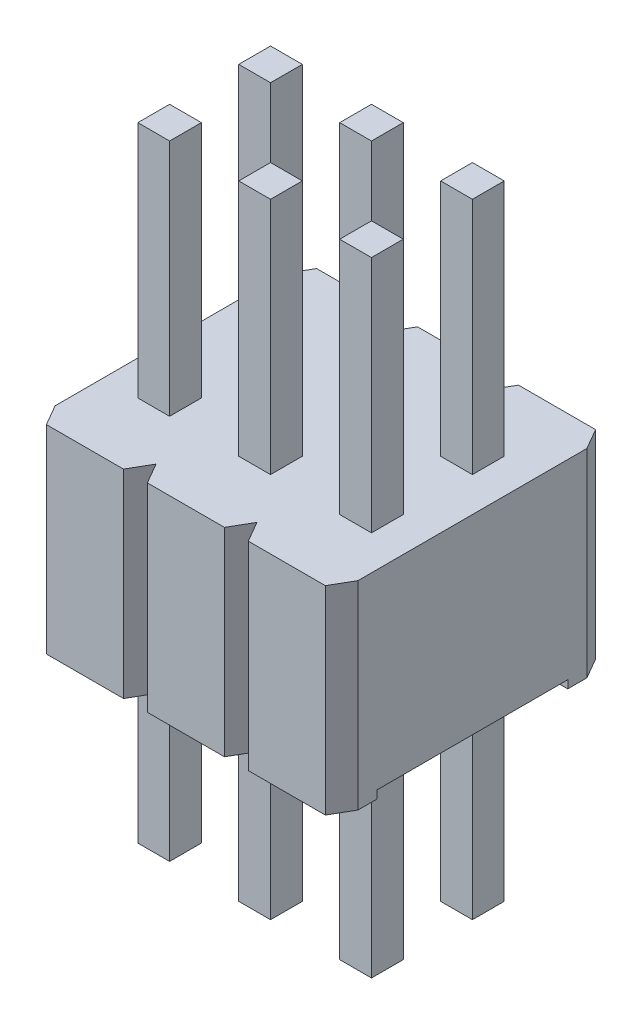
from build123d import *

# Parameters (mm, degrees)
SKETCH1_W             = 3.81
SKETCH1_H             = 3.4
BOSS_EXTRUDE1_DEPTH   = 2.5
CUT_EXTRUDE1_DEPTH    = 2.5
CUT_EXTRUDE2_DEPTH    = 2.5
CUT_EXTRUDE3_DEPTH    = 2.5
SKETCH5_W             = 2.4
SKETCH5_H             = 0.1
CUT_EXTRUDE4_DEPTH    = 4.81
CUT_EXTRUDE5_DEPTH    = 2.5
SKETCH7_W             = 0.4
SKETCH7_H             = 0.4
BOSS_EXTRUDE2_DEPTH   = 2.45
SKETCH8_W             = 0.4
SKETCH8_H             = 0.4
BOSS_EXTRUDE3_DEPTH   = 2.45
SKETCH9_W             = 0.4
SKETCH9_H             = 0.4
BOSS_EXTRUDE4_DEPTH   = 2.45
SKETCH10_W            = 0.4
SKETCH10_H            = 0.4
BOSS_EXTRUDE5_DEPTH   = 2.45
SKETCH11_W            = 0.4
SKETCH11_H            = 0.4
BOSS_EXTRUDE6_DEPTH   = 2.45
SKETCH12_W            = 0.4
SKETCH12_H            = 0.4
BOSS_EXTRUDE7_DEPTH   = 2.45
SKETCH13_W            = 0.4
SKETCH13_H            = 0.4
BOSS_EXTRUDE8_DEPTH   = 3
SKETCH14_W            = 0.4
SKETCH14_H            = 0.4
BOSS_EXTRUDE9_DEPTH   = 3
SKETCH15_W            = 0.4
SKETCH15_H            = 0.4
BOSS_EXTRUDE10_DEPTH  = 3
SKETCH16_W            = 0.4
SKETCH16_H            = 0.4
BOSS_EXTRUDE11_DEPTH  = 3
SKETCH17_W            = 0.4
SKETCH17_H            = 0.4
BOSS_EXTRUDE12_DEPTH  = 3
SKETCH18_W            = 0.4
SKETCH18_H            = 0.4
BOSS_EXTRUDE13_DEPTH  = 3
CHAMFER1_SIZE         = 0.15
CHAMFER1_SIZE2        = 0.26
CHAMFER1_PART_2_SIZE  = 0.15
CHAMFER1_PART_2_SIZE2 = 0.26
CHAMFER2_SIZE         = 0.26
CHAMFER2_SIZE2        = 0.15
CHAMFER2_PART_2_SIZE  = 0.26
CHAMFER2_PART_2_SIZE2 = 0.15


with BuildPart() as part:
    # Sketch1 → Boss-Extrude1 (new body)
    with BuildSketch(Plane(origin=(0, 2.5, 0), x_dir=(1, 0, 0), z_dir=(0, 1, 0))):
        with Locations((1.27, 0)):
            Rectangle(SKETCH1_W, SKETCH1_H)
    extrude(amount=-BOSS_EXTRUDE1_DEPTH)

    # Sketch2 → Cut-Extrude1 (cut)
    with BuildSketch(Plane.XZ):
        Polygon((0.785, 1.7), (0.485, 1.7), (0.635, 1.44), align=None)
    extrude(amount=-CUT_EXTRUDE1_DEPTH, mode=Mode.SUBTRACT)

    # Sketch3 → Cut-Extrude2 (cut)
    with BuildSketch(Plane.XZ):
        Polygon((1.755, -1.7), (2.055, -1.7), (1.905, -1.44), align=None)
    extrude(amount=-CUT_EXTRUDE2_DEPTH, mode=Mode.SUBTRACT)

    # Sketch4 → Cut-Extrude3 (cut)
    with BuildSketch(Plane.XZ):
        Polygon((0.485, -1.7), (0.785, -1.7), (0.635, -1.44), align=None)
    extrude(amount=-CUT_EXTRUDE3_DEPTH, mode=Mode.SUBTRACT)

    # Sketch5 → Cut-Extrude4 (cut, through all)
    with BuildSketch(Plane(origin=(3.175, 0, 0), x_dir=(0, 0, -1), z_dir=(1, 0, 0))):
        with Locations((0, 0.05)):
            Rectangle(SKETCH5_W, SKETCH5_H)
    extrude(amount=-CUT_EXTRUDE4_DEPTH, mode=Mode.SUBTRACT)

    # Sketch6 → Cut-Extrude5 (cut)
    with BuildSketch(Plane.XZ):
        Polygon((2.055, 1.7), (1.755, 1.7), (1.905, 1.44), align=None)
    extrude(amount=-CUT_EXTRUDE5_DEPTH, mode=Mode.SUBTRACT)

    # Sketch7 → Boss-Extrude2 (add)
    with BuildSketch(Plane.XZ.offset(-0.1)):
        with Locations((2.54, 0.635)):
            Rectangle(SKETCH7_W, SKETCH7_H)
    extrude(amount=BOSS_EXTRUDE2_DEPTH)

    # Sketch8 → Boss-Extrude3 (add)
    with BuildSketch(Plane.XZ.offset(-0.1)):
        with Locations((2.54, -0.635)):
            Rectangle(SKETCH8_W, SKETCH8_H)
    extrude(amount=BOSS_EXTRUDE3_DEPTH)

    # Sketch9 → Boss-Extrude4 (add)
    with BuildSketch(Plane.XZ.offset(-0.1)):
        with Locations((1.27, 0.635)):
            Rectangle(SKETCH9_W, SKETCH9_H)
    extrude(amount=BOSS_EXTRUDE4_DEPTH)

    # Sketch10 → Boss-Extrude5 (add)
    with BuildSketch(Plane.XZ.offset(-0.1)):
        with Locations((1.27, -0.635)):
            Rectangle(SKETCH10_W, SKETCH10_H)
    extrude(amount=BOSS_EXTRUDE5_DEPTH)

    # Sketch11 → Boss-Extrude6 (add)
    with BuildSketch(Plane.XZ.offset(-0.1)):
        with Locations((0, 0.635)):
            Rectangle(SKETCH11_W, SKETCH11_H)
    extrude(amount=BOSS_EXTRUDE6_DEPTH)

    # Sketch12 → Boss-Extrude7 (add)
    with BuildSketch(Plane.XZ.offset(-0.1)):
        with Locations((0, -0.635)):
            Rectangle(SKETCH12_W, SKETCH12_H)
    extrude(amount=BOSS_EXTRUDE7_DEPTH)

    # Sketch13 → Boss-Extrude8 (add)
    with BuildSketch(Plane(origin=(0, 2.5, 0), x_dir=(-1, 0, 0), z_dir=(0, 1, 0))):
        with Locations((-2.54, 0.635)):
            Rectangle(SKETCH13_W, SKETCH13_H)
    extrude(amount=BOSS_EXTRUDE8_DEPTH)

    # Sketch14 → Boss-Extrude9 (add)
    with BuildSketch(Plane(origin=(0, 2.5, 0), x_dir=(-1, 0, 0), z_dir=(0, 1, 0))):
        with Locations((-2.54, -0.635)):
            Rectangle(SKETCH14_W, SKETCH14_H)
    extrude(amount=BOSS_EXTRUDE9_DEPTH)

    # Sketch15 → Boss-Extrude10 (add)
    with BuildSketch(Plane(origin=(0, 2.5, 0), x_dir=(-1, 0, 0), z_dir=(0, 1, 0))):
        with Locations((-1.27, 0.635)):
            Rectangle(SKETCH15_W, SKETCH15_H)
    extrude(amount=BOSS_EXTRUDE10_DEPTH)

    # Sketch16 → Boss-Extrude11 (add)
    with BuildSketch(Plane(origin=(0, 2.5, 0), x_dir=(-1, 0, 0), z_dir=(0, 1, 0))):
        with Locations((-1.27, -0.635)):
            Rectangle(SKETCH16_W, SKETCH16_H)
    extrude(amount=BOSS_EXTRUDE11_DEPTH)

    # Sketch17 → Boss-Extrude12 (add)
    with BuildSketch(Plane(origin=(0, 2.5, 0), x_dir=(-1, 0, 0), z_dir=(0, 1, 0))):
        with Locations((0, 0.635)):
            Rectangle(SKETCH17_W, SKETCH17_H)
    extrude(amount=BOSS_EXTRUDE12_DEPTH)

    # Sketch18 → Boss-Extrude13 (add)
    with BuildSketch(Plane(origin=(0, 2.5, 0), x_dir=(-1, 0, 0), z_dir=(0, 1, 0))):
        with Locations((0, -0.635)):
            Rectangle(SKETCH18_W, SKETCH18_H)
    extrude(amount=BOSS_EXTRUDE13_DEPTH)

    # Chamfer1
    chamfer1_edges = [part.edges().sort_by_distance(p)[0] for p in [
        (-0.635, 1.25, 1.7),
    ]]
    chamfer1_side = [part.faces().sort_by_distance(p)[0] for p in [
        (-0.075, 1.25, 1.7),
    ]]
    chamfer(chamfer1_edges, length=CHAMFER1_SIZE, length2=CHAMFER1_SIZE2, reference=chamfer1_side[0])

    # Chamfer1 part 2
    chamfer1_part_2_edges = [part.edges().sort_by_distance(p)[0] for p in [
        (3.175, 1.25, -1.7),
    ]]
    chamfer1_part_2_side = [part.faces().sort_by_distance(p)[0] for p in [
        (2.615, 1.25, -1.7),
    ]]
    chamfer(chamfer1_part_2_edges, length=CHAMFER1_PART_2_SIZE, length2=CHAMFER1_PART_2_SIZE2, reference=chamfer1_part_2_side[0])

    # Chamfer2
    chamfer2_edges = [part.edges().sort_by_distance(p)[0] for p in [
        (-0.635, 1.25, -1.7),
    ]]
    chamfer2_side = [part.faces().sort_by_distance(p)[0] for p in [
        (-0.635, 1.287844941, -0.134099869),
    ]]
    chamfer(chamfer2_edges, length=CHAMFER2_SIZE, length2=CHAMFER2_SIZE2, reference=chamfer2_side[0])

    # Chamfer2 part 2
    chamfer2_part_2_edges = [part.edges().sort_by_distance(p)[0] for p in [
        (3.175, 1.25, 1.7),
    ]]
    chamfer2_part_2_side = [part.faces().sort_by_distance(p)[0] for p in [
        (3.175, 1.287844941, 0.134099869),
    ]]
    chamfer(chamfer2_part_2_edges, length=CHAMFER2_PART_2_SIZE, length2=CHAMFER2_PART_2_SIZE2, reference=chamfer2_part_2_side[0])


solid = part.part
